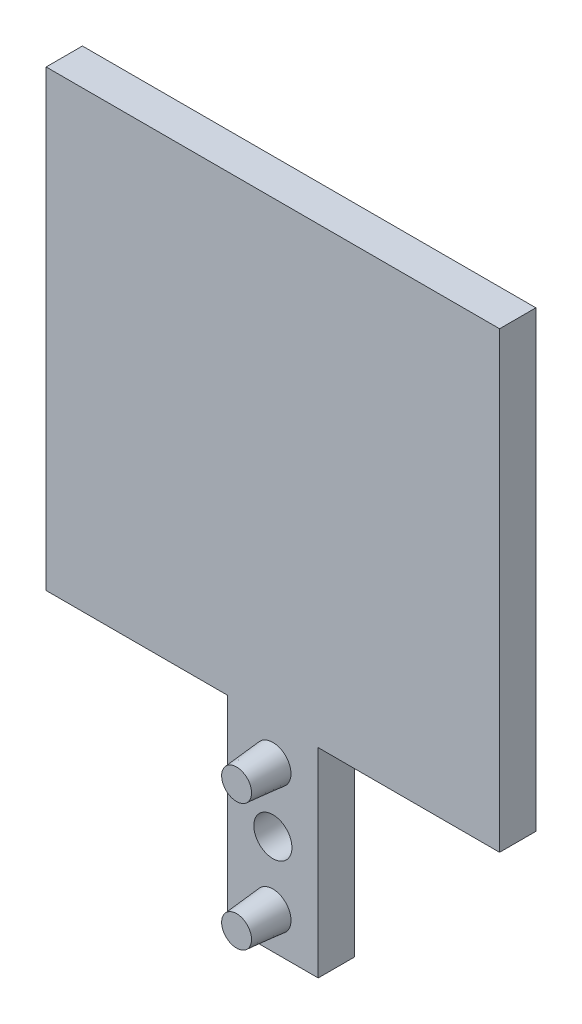
from build123d import *

# Parameters (mm, degrees)
BOSS_EXTRUDE1_DEPTH = 4
SKETCH2_R           = 2
BOSS_EXTRUDE2_DEPTH = 4
BOSS_EXTRUDE2_TAPER = 5
SKETCH3_R           = 2.1
CUT_EXTRUDE1_DEPTH  = 4


with BuildPart() as part:
    # Sketch1 → Boss-Extrude1 (new body)
    with BuildSketch(Plane.XY):
        Polygon((0, 0), (20, 0), (20, -22), (30, -22), (30, 0), (50, 0), (50, 50), (0, 50), align=None)
    extrude(amount=BOSS_EXTRUDE1_DEPTH)

    # Sketch2 → Boss-Extrude2 (add)
    with BuildSketch(Plane.XY.offset(4)):
        with Locations((25, -18)):
            Circle(SKETCH2_R)
        with Locations((25, -4)):
            Circle(SKETCH2_R)
    extrude(amount=BOSS_EXTRUDE2_DEPTH, taper=BOSS_EXTRUDE2_TAPER)

    # Sketch3 → Cut-Extrude1 (cut)
    with BuildSketch(Plane.XY.offset(4)):
        with Locations((25, -11)):
            Circle(SKETCH3_R)
    extrude(amount=-CUT_EXTRUDE1_DEPTH, mode=Mode.SUBTRACT)


solid = part.part
